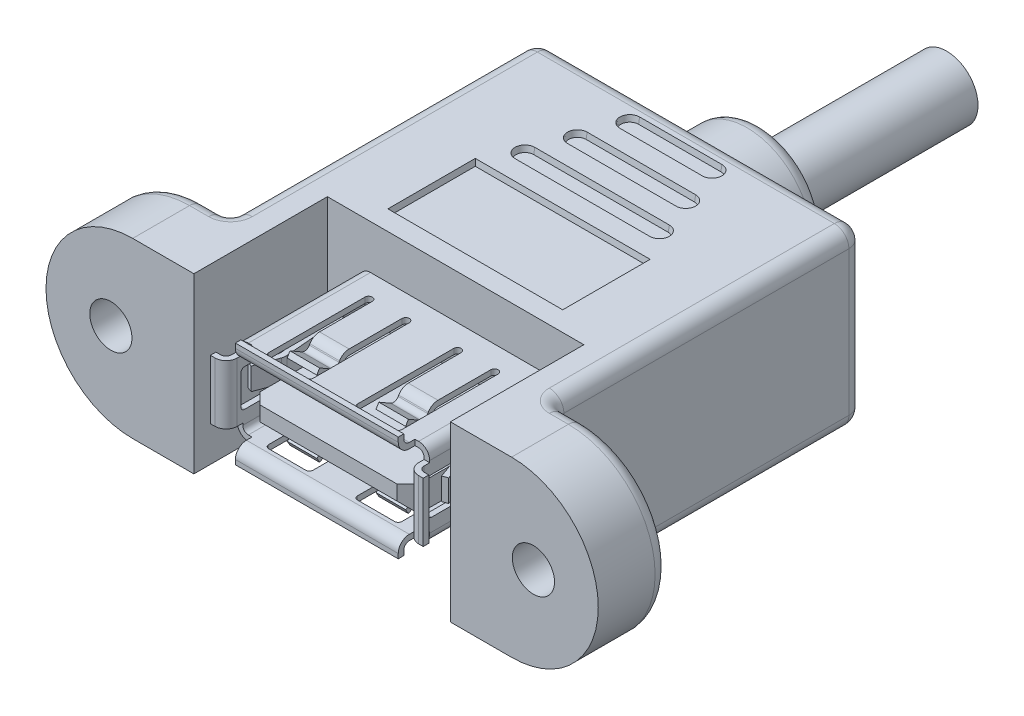
from build123d import *

# Parameters (mm, degrees)
EXTRUDE1_DEPTH     = 5.95
EXTRUDE3_DEPTH     = 4.9
SKETCH5_R          = 1.4478
CUT_EXTRUDE1_DEPTH = 4.9
SKETCH6_W          = 4.45
SKETCH6_H          = 4.2
SKETCH9_R          = 2.15
EXTRUDE5_DEPTH     = 12.7
SKETCH7_W          = 12
SKETCH7_H          = 6
CUT_EXTRUDE2_DEPTH = 0.4
CUT_EXTRUDE2_TAPER = 10
SKETCH8_W          = 12
SKETCH8_H          = 6
CUT_EXTRUDE3_DEPTH = 0.4
CUT_EXTRUDE3_TAPER = 10
FILLET1_R          = 0.5
EXTRUDE6_DEPTH     = 8.382
SKETCH11_W         = 0.381
SKETCH11_H         = 4.064
SKETCH11_W_2       = 11.176
SKETCH11_H_2       = 0.381
EXTRUDE7_DEPTH     = 0.254
EXTRUDE8_DEPTH     = 11.176
EXTRUDE9_DEPTH     = 4.064
CUT_EXTRUDE4_DEPTH = 5.842
CUT_EXTRUDE5_DEPTH = 13.462
EXTRUDE10_DEPTH    = 2.032
EXTRUDE11_DEPTH    = 2.032
EXTRUDE12_DEPTH    = 1.524
SKETCH21_W         = 10.922
SKETCH21_H         = 1.778
EXTRUDE14_DEPTH    = 8.7376
CHAMFER2_SIZE      = 0.762
FILLET2_R          = 1


with BuildPart() as part:
    # Sketch1 → Extrude1 (new body, symmetric)
    with BuildSketch(Plane(origin=(0, 0, 0), x_dir=(1, 0, 0), z_dir=(0, 1, 0))):
        with BuildLine():
            Line((-8.8, 0), (-8.8, -9.16))
            Line((-8.8, -9.16), (-11.19, -9.16))
            Line((-11.19, -9.16), (-11.19, 15.8))
            ThreePointArc((-11.19, 15.8), (-10.897106781, 16.507106781), (-10.19, 16.8))
            Line((-10.19, 16.8), (10.19, 16.8))
            ThreePointArc((10.19, 16.8), (10.897106781, 16.507106781), (11.19, 15.8))
            Line((11.19, 15.8), (11.19, -9.16))
            Line((11.19, -9.16), (8.8, -9.16))
            Line((8.8, -9.16), (8.8, 0))
            Line((8.8, 0), (-8.8, 0))
        make_face()
    extrude(amount=EXTRUDE1_DEPTH, both=True)

    # Sketch3 → Extrude3 (add)
    with BuildSketch(Plane.XY.offset(9.16)):
        with BuildLine():
            Line((8.8, 5.95), (13, 5.95))
            ThreePointArc((13, 5.95), (18.95, 0), (13, -5.95))
            Line((13, -5.95), (8.8, -5.95))
            Line((8.8, -5.95), (8.8, 5.95))
        make_face()
        with BuildLine():
            Line((-8.8, 5.95), (-13, 5.95))
            ThreePointArc((-13, 5.95), (-18.95, 0), (-13, -5.95))
            Line((-13, -5.95), (-8.8, -5.95))
            Line((-8.8, -5.95), (-8.8, 5.95))
        make_face()
    extrude(amount=-EXTRUDE3_DEPTH)

    # Sketch5 → Cut-Extrude1 (cut)
    with BuildSketch(Plane.XY.offset(9.16)):
        with Locations((-14.5, 0)):
            Circle(SKETCH5_R)
        with Locations((14.5, 0)):
            Circle(SKETCH5_R)
    extrude(amount=-CUT_EXTRUDE1_DEPTH, mode=Mode.SUBTRACT)

    # Sketch6 → Revolve1 (revolve)
    with BuildSketch(Plane(origin=(0, 0, 0), x_dir=(1, 0, 0), z_dir=(0, 1, 0))):
        with Locations((2.225, 18.9)):
            Rectangle(SKETCH6_W, SKETCH6_H)
    revolve(axis=Axis((0, 0, -27.379986608), (0, 0, 1)))

    # Sketch9 → Extrude5 (add)
    with BuildSketch(Plane(origin=(0, 0, -21), x_dir=(-1, 0, 0), z_dir=(0, 0, -1))):
        Circle(SKETCH9_R)
    extrude(amount=EXTRUDE5_DEPTH)

    # Sketch7 → Cut-Extrude2 (cut)
    with BuildSketch(Plane.XZ.offset(5.95)):
        with Locations((0, -4.35)):
            Rectangle(SKETCH7_W, SKETCH7_H)
        with BuildLine():
            ThreePointArc((-4.616860801, -8.7), (-5.291860801, -9.375), (-4.616860801, -10.05))
            Line((-4.616860801, -10.05), (4.616860801, -10.05))
            ThreePointArc((4.616860801, -10.05), (5.291860801, -9.375), (4.616860801, -8.7))
            Line((4.616860801, -8.7), (-4.616860801, -8.7))
        make_face()
        with BuildLine():
            ThreePointArc((-3.720930401, -11.4), (-4.395930401, -12.075), (-3.720930401, -12.75))
            Line((-3.720930401, -12.75), (3.720930401, -12.75))
            ThreePointArc((3.720930401, -12.75), (4.395930401, -12.075), (3.720930401, -11.4))
            Line((3.720930401, -11.4), (-3.720930401, -11.4))
        make_face()
        with BuildLine():
            ThreePointArc((-2.825, -14.1), (-3.5, -14.775), (-2.825, -15.45))
            Line((-2.825, -15.45), (2.825, -15.45))
            ThreePointArc((2.825, -15.45), (3.5, -14.775), (2.825, -14.1))
            Line((2.825, -14.1), (-2.825, -14.1))
        make_face()
    extrude(amount=-CUT_EXTRUDE2_DEPTH, taper=CUT_EXTRUDE2_TAPER, mode=Mode.SUBTRACT)

    # Sketch8 → Cut-Extrude3 (cut)
    with BuildSketch(Plane(origin=(0, 5.95, 0), x_dir=(-1, 0, 0), z_dir=(0, 1, 0))):
        with BuildLine():
            Line((4.616860801, -8.7), (-4.616860801, -8.7))
            ThreePointArc((-4.616860801, -8.7), (-5.291860801, -9.375), (-4.616860801, -10.05))
            Line((-4.616860801, -10.05), (4.616860801, -10.05))
            ThreePointArc((4.616860801, -10.05), (5.291860801, -9.375), (4.616860801, -8.7))
        make_face()
        with Locations((0, -4.35)):
            Rectangle(SKETCH8_W, SKETCH8_H)
        with BuildLine():
            Line((2.825, -14.1), (-2.825, -14.1))
            ThreePointArc((-2.825, -14.1), (-3.5, -14.775), (-2.825, -15.45))
            Line((-2.825, -15.45), (2.825, -15.45))
            ThreePointArc((2.825, -15.45), (3.5, -14.775), (2.825, -14.1))
        make_face()
        with BuildLine():
            Line((3.720930401, -11.4), (-3.720930401, -11.4))
            ThreePointArc((-3.720930401, -11.4), (-4.395930401, -12.075), (-3.720930401, -12.75))
            Line((-3.720930401, -12.75), (3.720930401, -12.75))
            ThreePointArc((3.720930401, -12.75), (4.395930401, -12.075), (3.720930401, -11.4))
        make_face()
    extrude(amount=-CUT_EXTRUDE3_DEPTH, taper=CUT_EXTRUDE3_TAPER, mode=Mode.SUBTRACT)

    # Fillet1
    fillet1_edges = [part.edges().sort_by_distance(p)[0] for p in [
        (11.19, 0, 4.26),
        (-11.19, 0, 4.26),
    ]]
    fillet(fillet1_edges, radius=FILLET1_R)

    # Sketch10 → Extrude6 (add)
    with BuildSketch(Plane.XY):
        with BuildLine():
            Line((-5.842, 2.921), (5.842, 2.921))
            ThreePointArc((5.842, 2.921), (6.380815367, 2.697815367), (6.604, 2.159))
            Line((6.604, 2.159), (6.604, -2.159))
            ThreePointArc((6.604, -2.159), (6.380815367, -2.697815367), (5.842, -2.921))
            Line((5.842, -2.921), (-5.842, -2.921))
            ThreePointArc((-5.842, -2.921), (-6.380815367, -2.697815367), (-6.604, -2.159))
            Line((-6.604, -2.159), (-6.604, 2.159))
            ThreePointArc((-6.604, 2.159), (-6.380815367, 2.697815367), (-5.842, 2.921))
        make_face()
        with BuildLine():
            Line((-5.842, 2.54), (5.842, 2.54))
            ThreePointArc((5.842, 2.54), (6.111407684, 2.428407684), (6.223, 2.159))
            Line((6.223, 2.159), (6.223, -2.159))
            ThreePointArc((6.223, -2.159), (6.111407684, -2.428407684), (5.842, -2.54))
            Line((5.842, -2.54), (-5.842, -2.54))
            ThreePointArc((-5.842, -2.54), (-6.111407684, -2.428407684), (-6.223, -2.159))
            Line((-6.223, -2.159), (-6.223, 2.159))
            ThreePointArc((-6.223, 2.159), (-6.111407684, 2.428407684), (-5.842, 2.54))
        make_face(mode=Mode.SUBTRACT)
    extrude(amount=EXTRUDE6_DEPTH)

    # Sketch11 → Extrude7 (add)
    with BuildSketch(Plane.XY.offset(8.382)):
        with Locations((-6.4135, 0)):
            Rectangle(SKETCH11_W, SKETCH11_H)
        with Locations((0, -2.7305)):
            Rectangle(SKETCH11_W_2, SKETCH11_H_2)
        with Locations((0, 2.7305)):
            Rectangle(SKETCH11_W_2, SKETCH11_H_2)
        with Locations((6.4135, 0)):
            Rectangle(SKETCH11_W, SKETCH11_H)
    extrude(amount=EXTRUDE7_DEPTH)

    # Sketch12 → Extrude8 (add)
    with BuildSketch(Plane(origin=(5.588, 0, 0), x_dir=(0, 0, -1), z_dir=(1, 0, 0))):
        with BuildLine():
            Line((-9.525, 3.302), (-9.525, 3.6195))
            Line((-9.525, 3.6195), (-9.144, 3.6195))
            Line((-9.144, 3.6195), (-9.144, 3.302))
            ThreePointArc((-9.144, 3.302), (-9.032407684, 3.032592316), (-8.763, 2.921))
            Line((-8.763, 2.921), (-8.382, 2.921))
            Line((-8.382, 2.921), (-8.382, 2.54))
            Line((-8.382, 2.54), (-8.763, 2.54))
            ThreePointArc((-8.763, 2.54), (-9.301815367, 2.763184633), (-9.525, 3.302))
        make_face()
        with BuildLine():
            Line((-9.525, -3.302), (-9.525, -3.6195))
            Line((-9.525, -3.6195), (-9.144, -3.6195))
            Line((-9.144, -3.6195), (-9.144, -3.302))
            ThreePointArc((-9.144, -3.302), (-9.032407684, -3.032592316), (-8.763, -2.921))
            Line((-8.763, -2.921), (-8.382, -2.921))
            Line((-8.382, -2.921), (-8.382, -2.54))
            Line((-8.382, -2.54), (-8.763, -2.54))
            ThreePointArc((-8.763, -2.54), (-9.301815367, -2.763184633), (-9.525, -3.302))
        make_face()
    extrude(amount=-EXTRUDE8_DEPTH)

    # Sketch13 → Extrude9 (add)
    with BuildSketch(Plane(origin=(0, 2.032, 0), x_dir=(-1, 0, 0), z_dir=(0, 1, 0))):
        with BuildLine():
            Line((-6.985, 9.144), (-7.3025, 9.144))
            Line((-7.3025, 9.144), (-7.3025, 9.525))
            Line((-7.3025, 9.525), (-6.985, 9.525))
            ThreePointArc((-6.985, 9.525), (-6.446184633, 9.301815367), (-6.223, 8.763))
            Line((-6.223, 8.763), (-6.223, 8.382))
            Line((-6.223, 8.382), (-6.604, 8.382))
            Line((-6.604, 8.382), (-6.604, 8.763))
            ThreePointArc((-6.604, 8.763), (-6.715592316, 9.032407684), (-6.985, 9.144))
        make_face()
        with BuildLine():
            Line((6.985, 9.144), (7.3025, 9.144))
            Line((7.3025, 9.144), (7.3025, 9.525))
            Line((7.3025, 9.525), (6.985, 9.525))
            ThreePointArc((6.985, 9.525), (6.446184633, 9.301815367), (6.223, 8.763))
            Line((6.223, 8.763), (6.223, 8.382))
            Line((6.223, 8.382), (6.604, 8.382))
            Line((6.604, 8.382), (6.604, 8.763))
            ThreePointArc((6.604, 8.763), (6.715592316, 9.032407684), (6.985, 9.144))
        make_face()
    extrude(amount=-EXTRUDE9_DEPTH)

    # Sketch14 → Cut-Extrude4 (cut)
    with BuildSketch(Plane(origin=(0, 2.921, 0), x_dir=(-1, 0, 0), z_dir=(0, 1, 0))):
        with BuildLine():
            Line((-2.032, 1.651), (-2.032, 2.159))
            Line((-2.032, 2.159), (-4.064, 2.159))
            Line((-4.064, 2.159), (-4.064, 1.651))
            ThreePointArc((-4.064, 1.651), (-4.318, 1.397), (-4.572, 1.651))
            Line((-4.572, 1.651), (-4.572, 8.255))
            ThreePointArc((-4.572, 8.255), (-4.497605122, 8.434605122), (-4.318, 8.509))
            Line((-4.318, 8.509), (-1.778, 8.509))
            ThreePointArc((-1.778, 8.509), (-1.598394878, 8.434605122), (-1.524, 8.255))
            Line((-1.524, 8.255), (-1.524, 1.651))
            ThreePointArc((-1.524, 1.651), (-1.778, 1.397), (-2.032, 1.651))
        make_face()
        with BuildLine():
            Line((4.572, 1.651), (4.572, 8.255))
            ThreePointArc((4.572, 8.255), (4.497605122, 8.434605122), (4.318, 8.509))
            Line((4.318, 8.509), (1.778, 8.509))
            ThreePointArc((1.778, 8.509), (1.598394878, 8.434605122), (1.524, 8.255))
            Line((1.524, 8.255), (1.524, 1.651))
            ThreePointArc((1.524, 1.651), (1.778, 1.397), (2.032, 1.651))
            Line((2.032, 1.651), (2.032, 2.159))
            Line((2.032, 2.159), (4.064, 2.159))
            Line((4.064, 2.159), (4.064, 1.651))
            ThreePointArc((4.064, 1.651), (4.318, 1.397), (4.572, 1.651))
        make_face()
    extrude(amount=-CUT_EXTRUDE4_DEPTH, mode=Mode.SUBTRACT)

    # Sketch15 → Cut-Extrude5 (cut)
    with BuildSketch(Plane(origin=(6.604, 0, 0), x_dir=(0, 0, -1), z_dir=(1, 0, 0))):
        with BuildLine():
            Line((-8.255, 1.27), (-1.651, 1.27))
            ThreePointArc((-1.651, 1.27), (-1.397, 1.016), (-1.651, 0.762))
            Line((-1.651, 0.762), (-1.905, 0.762))
            Line((-1.905, 0.762), (-1.905, -0.762))
            Line((-1.905, -0.762), (-1.651, -0.762))
            ThreePointArc((-1.651, -0.762), (-1.397, -1.016), (-1.651, -1.27))
            Line((-1.651, -1.27), (-8.255, -1.27))
            ThreePointArc((-8.255, -1.27), (-8.434605122, -1.195605122), (-8.509, -1.016))
            Line((-8.509, -1.016), (-8.509, 1.016))
            ThreePointArc((-8.509, 1.016), (-8.434605122, 1.195605122), (-8.255, 1.27))
        make_face()
    extrude(amount=-CUT_EXTRUDE5_DEPTH, mode=Mode.SUBTRACT)

    # Sketch17 → Extrude10 (add)
    with BuildSketch(Plane(origin=(4.064, 0, 0), x_dir=(0, 0, -1), z_dir=(1, 0, 0))):
        with BuildLine():
            Line((-5.934970453, 2.54), (-5.971632195, 2.4765))
            ThreePointArc((-5.971632195, 2.4765), (-6.202977817, 2.29898226), (-6.492087873, 2.337044321))
            Line((-6.492087873, 2.337044321), (-7.3025, 2.804935981))
            Line((-7.3025, 2.804935981), (-7.493, 2.474980302))
            Line((-7.493, 2.474980302), (-6.682587873, 2.007088642))
            ThreePointArc((-6.682587873, 2.007088642), (-6.104367761, 1.93096452), (-5.641676516, 2.286))
            Line((-5.641676516, 2.286), (-5.605014774, 2.3495))
            ThreePointArc((-5.605014774, 2.3495), (-5.465559095, 2.488955679), (-5.275059095, 2.54))
            Line((-5.275059095, 2.54), (-1.651, 2.54))
            Line((-1.651, 2.54), (-1.651, 2.921))
            Line((-1.651, 2.921), (-5.275059095, 2.921))
            ThreePointArc((-5.275059095, 2.921), (-5.656059095, 2.818911358), (-5.934970453, 2.54))
        make_face()
        with BuildLine():
            Line((-5.641676516, -2.286), (-5.605014774, -2.3495))
            ThreePointArc((-5.605014774, -2.3495), (-5.465559095, -2.488955679), (-5.275059095, -2.54))
            Line((-5.275059095, -2.54), (-1.651, -2.54))
            Line((-1.651, -2.54), (-1.651, -2.921))
            Line((-1.651, -2.921), (-5.275059095, -2.921))
            ThreePointArc((-5.275059095, -2.921), (-5.656059095, -2.818911358), (-5.934970453, -2.54))
            Line((-5.934970453, -2.54), (-5.971632195, -2.4765))
            ThreePointArc((-5.971632195, -2.4765), (-6.202977817, -2.29898226), (-6.492087873, -2.337044321))
            Line((-6.492087873, -2.337044321), (-7.3025, -2.804935981))
            Line((-7.3025, -2.804935981), (-7.493, -2.474980302))
            Line((-7.493, -2.474980302), (-6.682587873, -2.007088642))
            ThreePointArc((-6.682587873, -2.007088642), (-6.104367761, -1.93096452), (-5.641676516, -2.286))
        make_face()
    extrude(amount=-EXTRUDE10_DEPTH)

    # Sketch18 → Extrude11 (add)
    with BuildSketch(Plane(origin=(-2.032, 0, 0), x_dir=(0, 0, -1), z_dir=(1, 0, 0))):
        with BuildLine():
            Line((-5.934970453, 2.54), (-5.971632195, 2.4765))
            ThreePointArc((-5.971632195, 2.4765), (-6.202977817, 2.29898226), (-6.492087873, 2.337044321))
            Line((-6.492087873, 2.337044321), (-7.3025, 2.804935981))
            Line((-7.3025, 2.804935981), (-7.493, 2.474980302))
            Line((-7.493, 2.474980302), (-6.682587873, 2.007088642))
            ThreePointArc((-6.682587873, 2.007088642), (-6.104367761, 1.93096452), (-5.641676516, 2.286))
            Line((-5.641676516, 2.286), (-5.605014774, 2.3495))
            ThreePointArc((-5.605014774, 2.3495), (-5.465559095, 2.488955679), (-5.275059095, 2.54))
            Line((-5.275059095, 2.54), (-1.651, 2.54))
            Line((-1.651, 2.54), (-1.651, 2.921))
            Line((-1.651, 2.921), (-5.275059095, 2.921))
            ThreePointArc((-5.275059095, 2.921), (-5.656059095, 2.818911358), (-5.934970453, 2.54))
        make_face()
        with BuildLine():
            Line((-5.605014774, -2.3495), (-5.641676516, -2.286))
            ThreePointArc((-5.641676516, -2.286), (-6.104367761, -1.93096452), (-6.682587873, -2.007088642))
            Line((-6.682587873, -2.007088642), (-7.493, -2.474980302))
            Line((-7.493, -2.474980302), (-7.3025, -2.804935981))
            Line((-7.3025, -2.804935981), (-6.492087873, -2.337044321))
            ThreePointArc((-6.492087873, -2.337044321), (-6.202977817, -2.29898226), (-5.971632195, -2.4765))
            Line((-5.971632195, -2.4765), (-5.934970453, -2.54))
            ThreePointArc((-5.934970453, -2.54), (-5.656059095, -2.818911358), (-5.275059095, -2.921))
            Line((-5.275059095, -2.921), (-1.651, -2.921))
            Line((-1.651, -2.921), (-1.651, -2.54))
            Line((-1.651, -2.54), (-5.275059095, -2.54))
            ThreePointArc((-5.275059095, -2.54), (-5.465559095, -2.488955679), (-5.605014774, -2.3495))
        make_face()
    extrude(amount=-EXTRUDE11_DEPTH)

    # Sketch20 → Extrude12 (add)
    with BuildSketch(Plane(origin=(0, 0.762, 0), x_dir=(-1, 0, 0), z_dir=(0, 1, 0))):
        with BuildLine():
            Line((-6.60110036, 2.446143037), (-6.318017611, 5.681793662))
            ThreePointArc((-6.318017611, 5.681793662), (-6.319827299, 5.764730479), (-6.339544903, 5.845309675))
            Line((-6.339544903, 5.845309675), (-6.891826294, 7.362690325))
            Line((-6.891826294, 7.362690325), (-6.533803405, 7.493))
            Line((-6.533803405, 7.493), (-5.981522014, 5.975619349))
            ThreePointArc((-5.981522014, 5.975619349), (-5.942086807, 5.814460958), (-5.938467431, 5.648587324))
            Line((-5.938467431, 5.648587324), (-6.223, 2.396365181))
            Line((-6.223, 2.396365181), (-6.223, 1.651))
            Line((-6.223, 1.651), (-6.604, 1.651))
            Line((-6.604, 1.651), (-6.604, 2.379730362))
            ThreePointArc((-6.604, 2.379730362), (-6.603274745, 2.412968335), (-6.60110036, 2.446143037))
        make_face()
        with BuildLine():
            Line((6.60110036, 2.446143037), (6.318017611, 5.681793662))
            ThreePointArc((6.318017611, 5.681793662), (6.319827299, 5.764730479), (6.339544903, 5.845309675))
            Line((6.339544903, 5.845309675), (6.891826294, 7.362690325))
            Line((6.891826294, 7.362690325), (6.533803405, 7.493))
            Line((6.533803405, 7.493), (5.981522014, 5.975619349))
            ThreePointArc((5.981522014, 5.975619349), (5.942086807, 5.814460958), (5.938467431, 5.648587324))
            Line((5.938467431, 5.648587324), (6.223, 2.396365181))
            Line((6.223, 2.396365181), (6.223, 1.651))
            Line((6.223, 1.651), (6.604, 1.651))
            Line((6.604, 1.651), (6.604, 2.379730362))
            ThreePointArc((6.604, 2.379730362), (6.603274745, 2.412968335), (6.60110036, 2.446143037))
        make_face()
    extrude(amount=-EXTRUDE12_DEPTH)

    # Sketch21 → Extrude14 (add)
    with BuildSketch(Plane.XY):
        with Locations((0, -0.889)):
            Rectangle(SKETCH21_W, SKETCH21_H)
    extrude(amount=EXTRUDE14_DEPTH)

    # Chamfer2
    chamfer2_edges = [part.edges().sort_by_distance(p)[0] for p in [
        (-5.461, -0.889, 8.7376),
        (0, -1.778, 8.7376),
        (5.461, -0.889, 8.7376),
    ]]
    chamfer(chamfer2_edges, length=CHAMFER2_SIZE)

    # Fillet2
    fillet2_edges = [part.edges().sort_by_distance(p)[0] for p in [
        (-11.19, -5.95, -6.02),
        (-10.897106781, -5.95, -16.507106781),
        (0, -5.95, -16.8),
        (10.897106781, -5.95, -16.507106781),
        (10.897106781, 5.95, -16.507106781),
        (-12.345, 5.95, 4.26),
        (11.19, 5.95, -6.02),
        (11.19, -5.95, -6.02),
        (0, 5.95, -16.8),
        (12.345, -5.95, 4.26),
        (-11.336446609, -5.95, 4.113553391),
        (-11.336446609, 5.95, 4.113553391),
        (11.336446609, -5.95, 4.113553391),
        (11.336446609, 5.95, 4.113553391),
        (-10.897106781, 5.95, -16.507106781),
        (-11.19, 5.95, -6.02),
        (12.345, 5.95, 4.26),
        (18.95, 0, 4.26),
        (-12.345, -5.95, 4.26),
        (-18.95, 0, 4.26),
        (-4.45, 0, -21),
    ]]
    fillet(fillet2_edges, radius=FILLET2_R)


solid = part.part
